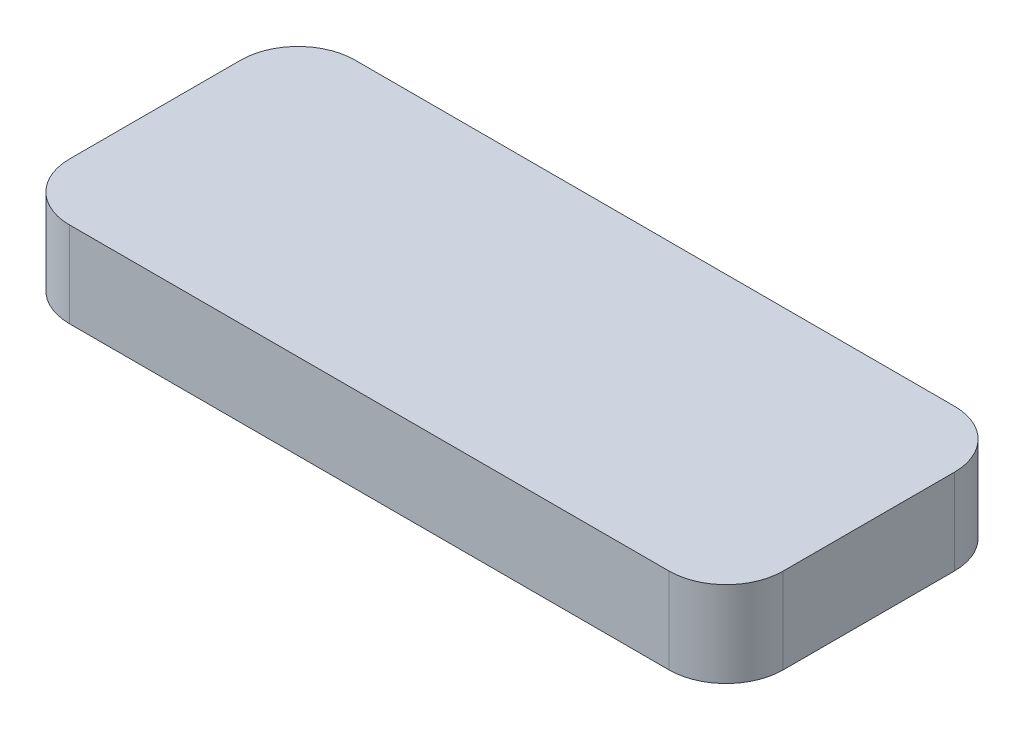
from build123d import *

# Parameters (mm, degrees)
SKETCH1_W           = 25
SKETCH1_H           = 10
BOSS_EXTRUDE1_DEPTH = 3
FILLET1_R           = 2


with BuildPart() as part:
    # Sketch1 → Boss-Extrude1 (new body)
    with BuildSketch(Plane(origin=(0, 0, 0), x_dir=(1, 0, 0), z_dir=(0, 1, 0))):
        Rectangle(SKETCH1_W, SKETCH1_H)
    extrude(amount=BOSS_EXTRUDE1_DEPTH)

    # Fillet1
    fillet1_edges = [part.edges().sort_by_distance(p)[0] for p in [
        (-12.5, 1.5, -5),
        (12.5, 1.5, -5),
        (12.5, 1.5, 5),
        (-12.5, 1.5, 5),
    ]]
    fillet(fillet1_edges, radius=FILLET1_R)


solid = part.part
